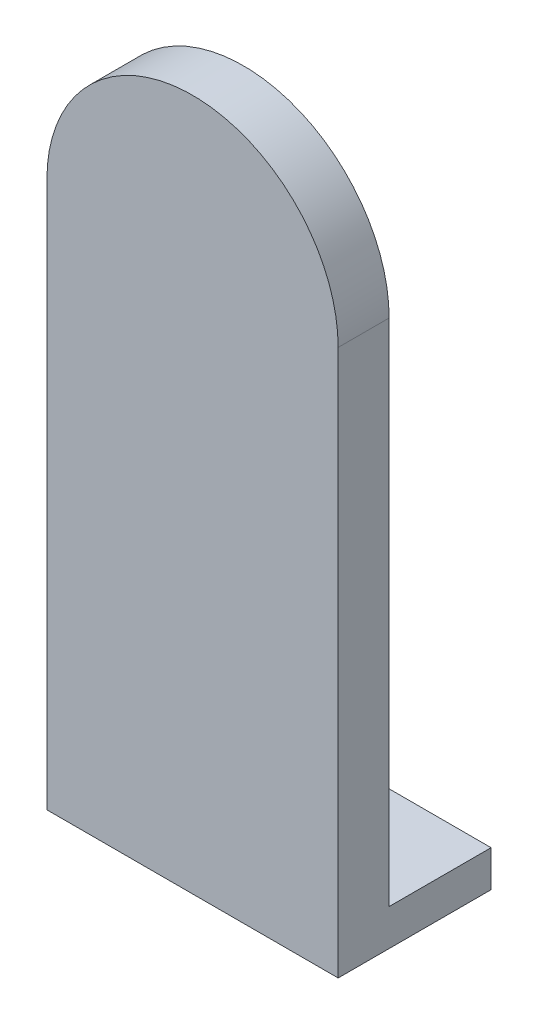
from build123d import *

# Parameters (mm, degrees)
BOSS_EXTRUDE1_DEPTH = 7
SKETCH2_R           = 5
BOSS_EXTRUDE2_DEPTH = 4
SKETCH3_W           = 40
SKETCH3_H           = 5
BOSS_EXTRUDE3_DEPTH = 14
SKETCH5_R           = 1.5
CUT_EXTRUDE1_DEPTH  = 6


with BuildPart() as part:
    # Sketch1 → Boss-Extrude1 (new body)
    with BuildSketch(Plane.XY):
        with BuildLine():
            Line((20, 0), (20, -75))
            Line((20, -75), (-20, -75))
            Line((-20, -75), (-20, 0))
            ThreePointArc((-20, 0), (0, 20), (20, 0))
        make_face()
    extrude(amount=BOSS_EXTRUDE1_DEPTH)

    # Sketch2 → Boss-Extrude2 (add)
    with BuildSketch(Plane(origin=(0, 0, 0), x_dir=(-1, 0, 0), z_dir=(0, 0, -1))):
        Circle(SKETCH2_R)
    extrude(amount=BOSS_EXTRUDE2_DEPTH)

    # Sketch3 → Boss-Extrude3 (add)
    with BuildSketch(Plane(origin=(0, 0, 0), x_dir=(-1, 0, 0), z_dir=(0, 0, -1))):
        with Locations((0, -72.5)):
            Rectangle(SKETCH3_W, SKETCH3_H)
    extrude(amount=BOSS_EXTRUDE3_DEPTH)

    # Sketch5 → Cut-Extrude1 (cut, through all)
    with BuildSketch(Plane(origin=(0, -70, 0), x_dir=(1, 0, 0), z_dir=(0, 1, 0))):
        with Locations((10, 7)):
            Circle(SKETCH5_R)
        with Locations((-10, 7)):
            Circle(SKETCH5_R)
    extrude(amount=-CUT_EXTRUDE1_DEPTH, mode=Mode.SUBTRACT)


solid = part.part
